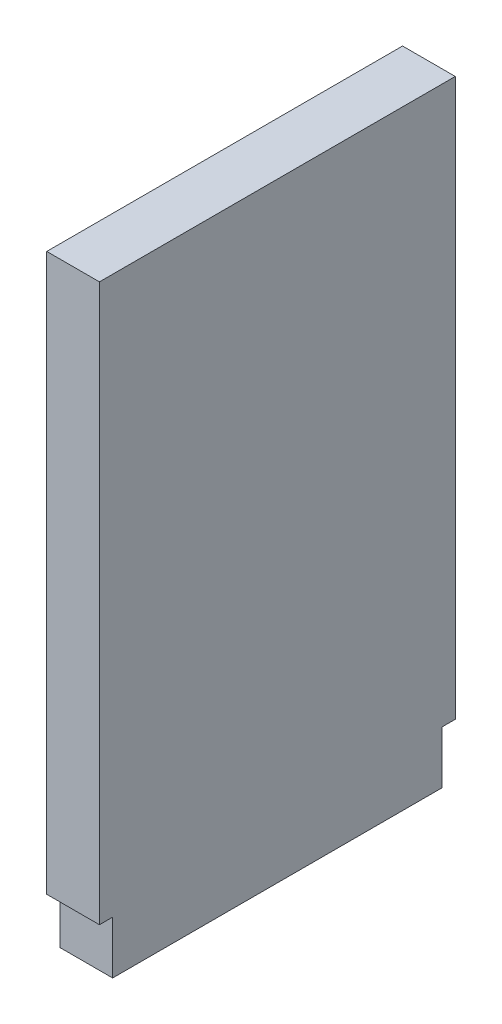
from build123d import *

# Parameters (mm, degrees)
EXTRUDE_1_DEPTH = 0.8


with BuildPart() as part:
    # 스케치3 → 보스-돌출1 (new body)
    with BuildSketch(Plane(origin=(0, 0, 0), x_dir=(0, 0, -1), z_dir=(1, 0, 0))):
        Polygon((-2.5, 0), (2.5, 0), (2.5, 0.8), (2.7, 0.8), (2.7, 9.25), (-2.7, 9.25), (-2.7, 0.8), (-2.5, 0.8), align=None)
    extrude(amount=EXTRUDE_1_DEPTH)


solid = part.part
